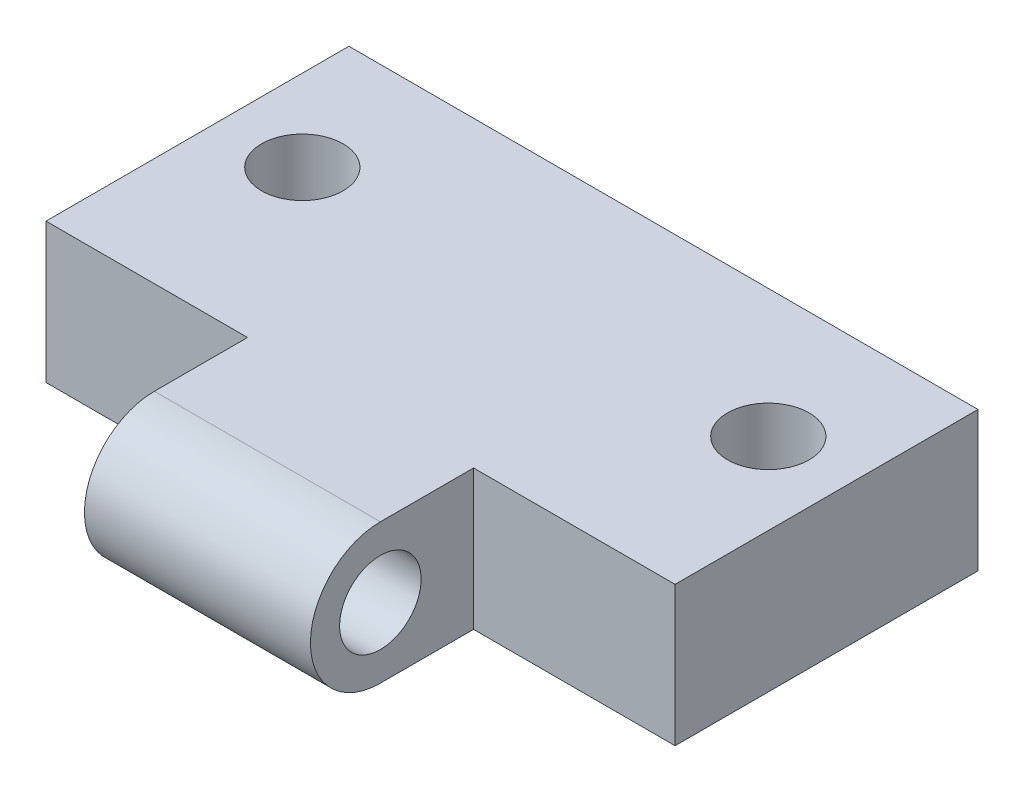
from build123d import *

# Parameters (mm, degrees)
SKETCH2_R           = 1.75
BOSS_EXTRUDE2_DEPTH = 27
SKETCH3_R           = 1.75
SKETCH3_W           = 8.65
SKETCH3_H           = 7
CUT_EXTRUDE1_DEPTH  = 30
SKETCH4_R           = 3
CUT_EXTRUDE2_DEPTH  = 3


with BuildPart() as part:
    # Sketch2 → Boss-Extrude2 (new body)
    with BuildSketch(Plane(origin=(0, 0, 0), x_dir=(0, 0, -1), z_dir=(1, 0, 0))):
        with BuildLine():
            Line((0, -3), (17, -3))
            Line((17, -3), (17, 3))
            Line((17, 3), (0, 3))
            ThreePointArc((0, 3), (-3, 0), (0, -3))
        make_face()
        Circle(SKETCH2_R, mode=Mode.SUBTRACT)
    extrude(amount=BOSS_EXTRUDE2_DEPTH)

    # Sketch3 → Cut-Extrude1 (cut)
    with BuildSketch(Plane.XZ.offset(3)):
        with Locations((3.5, -11.5)):
            Circle(SKETCH3_R)
        with Locations((23.5, -11.5)):
            Circle(SKETCH3_R)
        with Locations((22.675, -0.5)):
            Rectangle(SKETCH3_W, SKETCH3_H)
        with Locations((4.325, -0.5)):
            Rectangle(SKETCH3_W, SKETCH3_H)
    extrude(amount=-CUT_EXTRUDE1_DEPTH, mode=Mode.SUBTRACT)

    # Sketch4 → Cut-Extrude2 (cut)
    with BuildSketch(Plane.XZ.offset(3)):
        with Locations((3.5, -11.5)):
            Circle(SKETCH4_R)
        with Locations((23.5, -11.5)):
            Circle(SKETCH4_R)
    extrude(amount=-CUT_EXTRUDE2_DEPTH, mode=Mode.SUBTRACT)


solid = part.part
